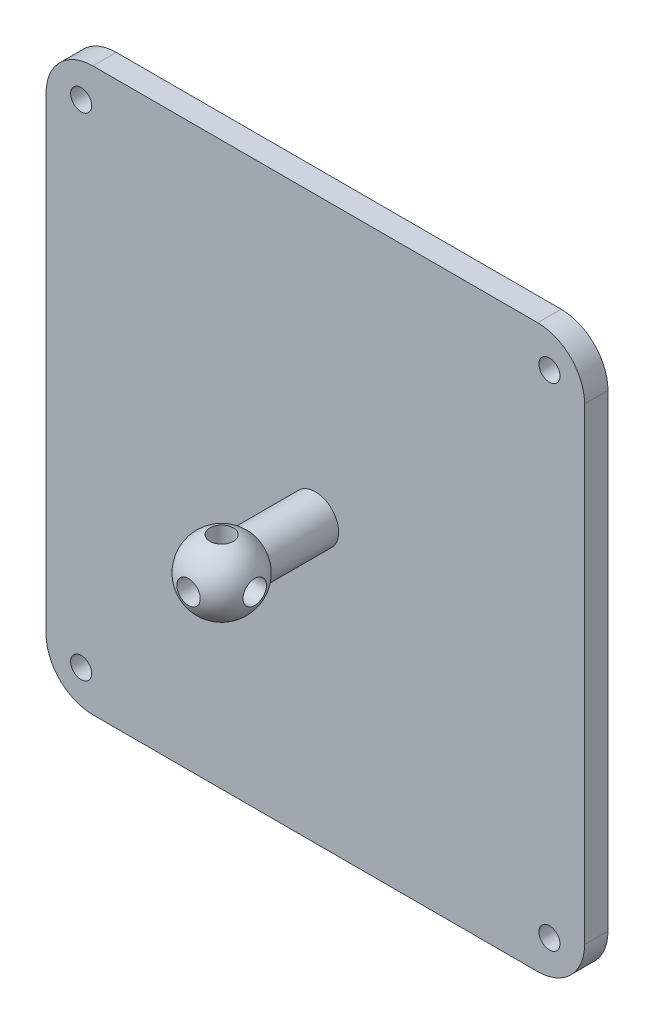
from build123d import *

# Parameters (mm, degrees)
SKETCH2_W           = 115
SKETCH2_H           = 120
SKETCH2_R           = 2.25
BOSS_EXTRUDE1_DEPTH = 5
SKETCH3_R           = 5
BOSS_EXTRUDE2_DEPTH = 20
SKETCH6_W           = 2.5
SKETCH6_H           = 18
SKETCH8_W           = 18
SKETCH8_H           = 2.5
SKETCH9_W           = 18
SKETCH9_H           = 2.5
FILLET1_R           = 10


with BuildPart() as part:
    # Sketch2 → Boss-Extrude1 (new body)
    with BuildSketch(Plane.XY):
        Rectangle(SKETCH2_W, SKETCH2_H)
        with Locations((50, 52.5)):
            Circle(SKETCH2_R, mode=Mode.SUBTRACT)
        with Locations((50, -52.5)):
            Circle(SKETCH2_R, mode=Mode.SUBTRACT)
        with Locations((-50, -52.5)):
            Circle(SKETCH2_R, mode=Mode.SUBTRACT)
        with Locations((-50, 52.5)):
            Circle(SKETCH2_R, mode=Mode.SUBTRACT)
    extrude(amount=-BOSS_EXTRUDE1_DEPTH)

    # Sketch3 → Boss-Extrude2 (add)
    with BuildSketch(Plane.XY):
        Circle(SKETCH3_R)
    extrude(amount=BOSS_EXTRUDE2_DEPTH)

    # Sketch4 → Revolve3 (revolve)
    with BuildSketch(Plane(origin=(0, 0, 0), x_dir=(1, 0, 0), z_dir=(0, 1, 0))):
        with BuildLine():
            Line((0, -12.5), (0, -27.5))
            ThreePointArc((0, -27.5), (7.5, -20), (0, -12.5))
        make_face()
    revolve(axis=Axis((0, 0, -22.886774461), (0, 0, 1)))

    # Sketch6 → Cut-Revolve1 (revolve, cut)
    with BuildSketch(Plane(origin=(0, 0, 0), x_dir=(0, 0, -1), z_dir=(1, 0, 0))):
        with Locations((-18.75, 6)):
            Rectangle(SKETCH6_W, SKETCH6_H)
    revolve(axis=Axis((0, 42.177542576, 20), (0, -1, 0)), mode=Mode.SUBTRACT)

    # Sketch8 → Cut-Revolve2 (revolve, cut)
    with BuildSketch(Plane(origin=(0, 0, 0), x_dir=(0, 0, -1), z_dir=(1, 0, 0))):
        with Locations((-26, 1.25)):
            Rectangle(SKETCH8_W, SKETCH8_H)
    revolve(axis=Axis((0, 0, 46.4260406), (0, 0, -1)), mode=Mode.SUBTRACT)

    # Sketch9 → Cut-Revolve3 (revolve, cut)
    with BuildSketch(Plane(origin=(0, 0, 0), x_dir=(1, 0, 0), z_dir=(0, 1, 0))):
        with Locations((6, -18.75)):
            Rectangle(SKETCH9_W, SKETCH9_H)
    revolve(axis=Axis((-16.030191757, 0, 20), (1, 0, 0)), mode=Mode.SUBTRACT)

    # Fillet1
    fillet1_edges = [part.edges().sort_by_distance(p)[0] for p in [
        (-57.5, 60, -2.5),
        (57.5, 60, -2.5),
        (57.5, -60, -2.5),
        (-57.5, -60, -2.5),
    ]]
    fillet(fillet1_edges, radius=FILLET1_R)


solid = part.part
